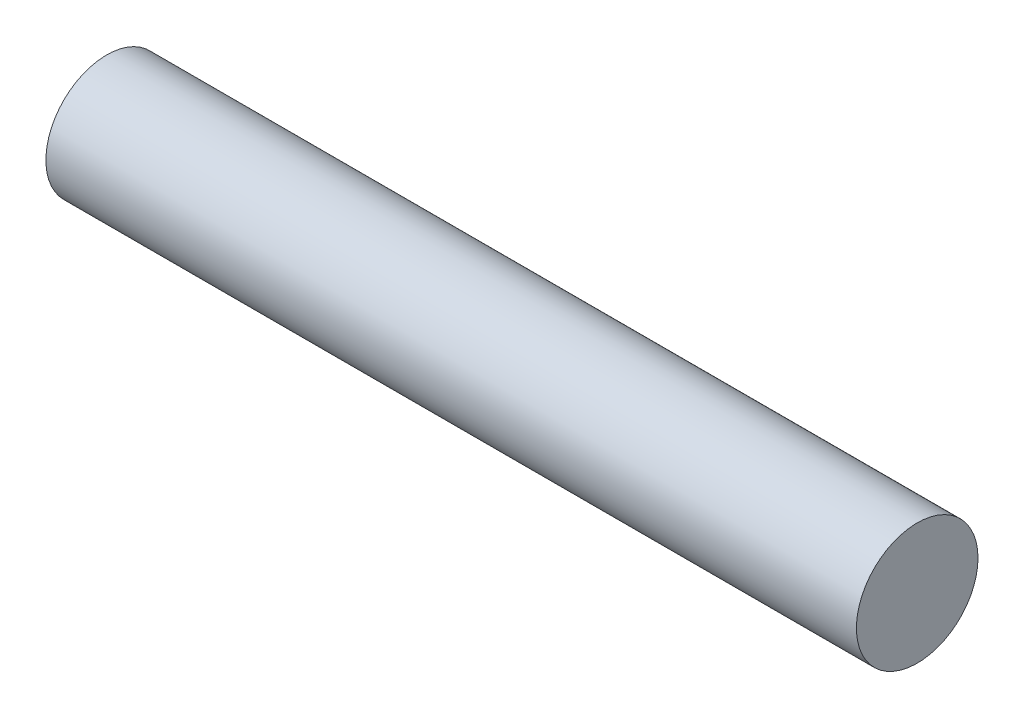
from build123d import *

# Parameters (mm, degrees)
SKETCH1_R           = 4.5
BOSS_EXTRUDE1_DEPTH = 30


with BuildPart() as part:
    # Sketch1 → Boss-Extrude1 (new body, symmetric)
    with BuildSketch(Plane(origin=(0, 0, 0), x_dir=(0, 0, -1), z_dir=(1, 0, 0))):
        Circle(SKETCH1_R)
    extrude(amount=BOSS_EXTRUDE1_DEPTH, both=True)


solid = part.part
